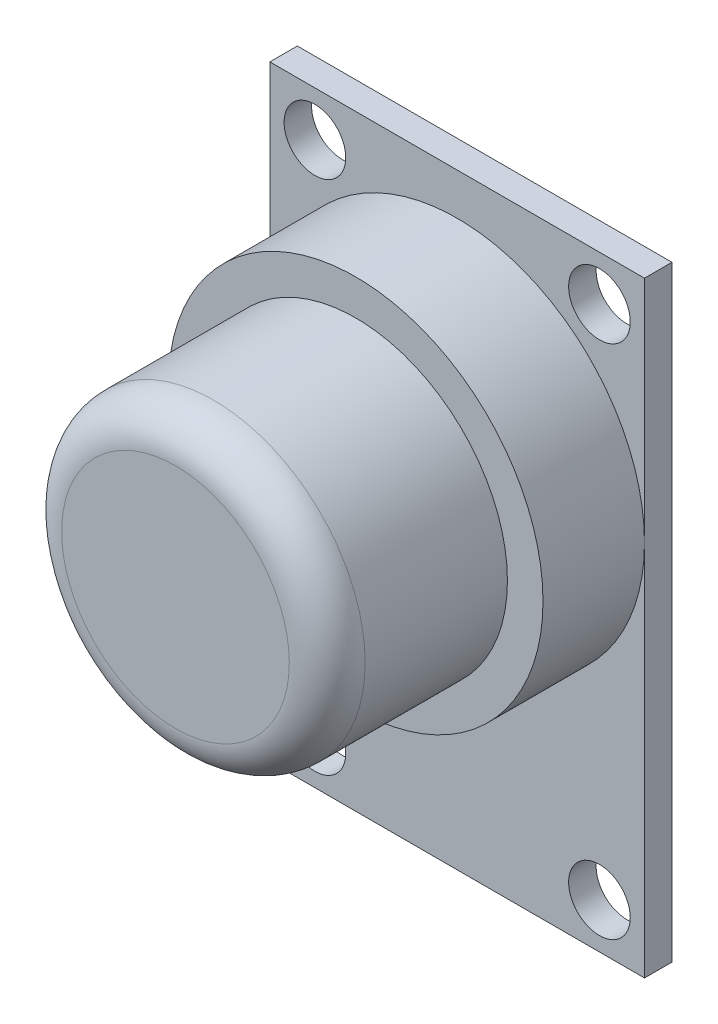
from build123d import *

# Parameters (mm, degrees)
SKETCH1_W           = 19.75
SKETCH1_H           = 31.95
BOSS_EXTRUDE1_DEPTH = 1.45
SKETCH2_R           = 1.625
CUT_EXTRUDE1_DEPTH  = 2.45
SKETCH3_R           = 9.875
BOSS_EXTRUDE2_DEPTH = 5.35
SKETCH4_R           = 8
BOSS_EXTRUDE3_DEPTH = 9.5
FILLET1_R           = 2


with BuildPart() as part:
    # Sketch1 → Boss-Extrude1 (new body)
    with BuildSketch(Plane.XY):
        Rectangle(SKETCH1_W, SKETCH1_H)
    extrude(amount=BOSS_EXTRUDE1_DEPTH)

    # Sketch2 → Cut-Extrude1 (cut, through all)
    with BuildSketch(Plane.XY.offset(1.45)):
        with Locations((-7.5, 13.6)):
            Circle(SKETCH2_R)
        with Locations((-7.5, -13.6)):
            Circle(SKETCH2_R)
        with Locations((7.5, -13.6)):
            Circle(SKETCH2_R)
        with Locations((7.5, 13.6)):
            Circle(SKETCH2_R)
    extrude(amount=-CUT_EXTRUDE1_DEPTH, mode=Mode.SUBTRACT)

    # Sketch3 → Boss-Extrude2 (add)
    with BuildSketch(Plane.XY.offset(1.45)):
        with Locations((0, 3.9)):
            Circle(SKETCH3_R)
    extrude(amount=BOSS_EXTRUDE2_DEPTH)

    # Sketch4 → Boss-Extrude3 (add)
    with BuildSketch(Plane.XY.offset(6.8)):
        with Locations((0, 3.9)):
            Circle(SKETCH4_R)
    extrude(amount=BOSS_EXTRUDE3_DEPTH)

    # Fillet1
    fillet1_edges = [part.edges().sort_by_distance(p)[0] for p in [
        (-8, 3.9, 16.3),
    ]]
    fillet(fillet1_edges, radius=FILLET1_R)


solid = part.part
